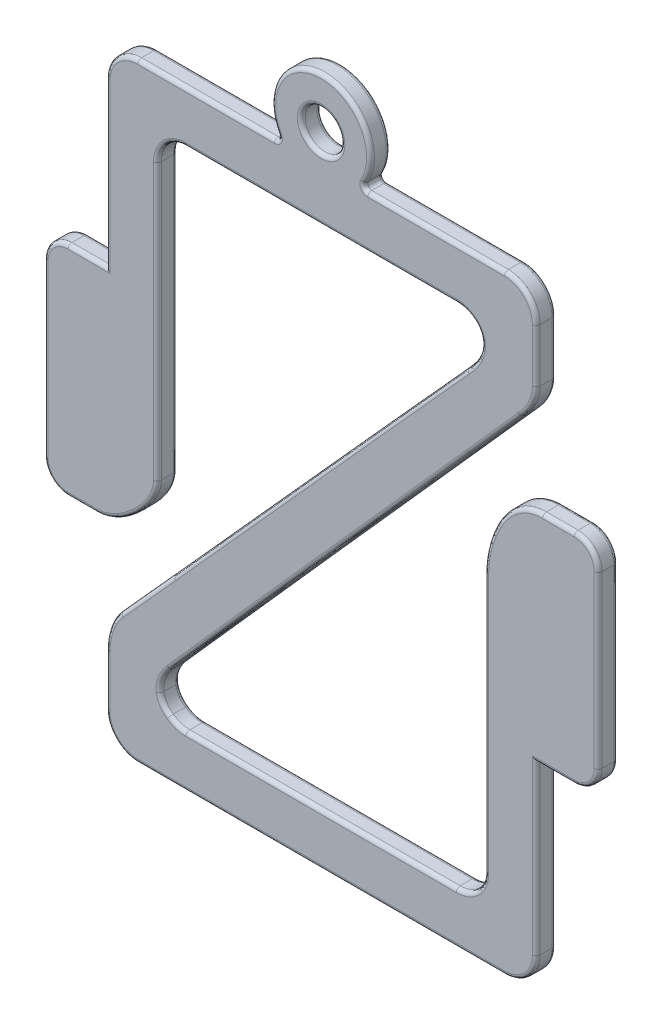
from build123d import *

# Parameters (mm, degrees)
MODEL_R             = 10
BOSS_EXTRUDE1_DEPTH = 10
FILLET1_R           = 2
SCALE1_SCALE        = 0.12


with BuildPart() as part:
    # Model → Boss-Extrude1 (new body)
    with BuildSketch(Plane.XY):
        with BuildLine():
            Line((214.526068033, -387.721577334), (400.098290163, -387.721577334))
            add(Edge.make_bspline(
                [(400.098290163, -387.721577334), (408.979915984, -387.721577334), (416.18012087, -380.521372266), (416.18012087, -371.639746221)],
                knots=[1, 1, 1, 1, 2, 2, 2, 2], degree=3))
            Line((416.18012087, -371.639746221), (416.18012087, -286.435471139))
            Line((416.18012087, -286.435471139), (435.328118703, -286.435471139))
            add(Edge.make_bspline(
                [(435.328118703, -286.435471139), (442.036770379, -286.435471139), (447.475543253, -280.996698128), (447.475543253, -274.288046283)],
                knots=[4, 4, 4, 4, 5, 5, 5, 5], degree=3))
            Line((447.475543253, -274.288046283), (447.475543253, -188.08165222))
            add(Edge.make_bspline(
                [(447.475543253, -188.08165222), (447.475543253, -181.373396469), (442.10093768, -175.935019553), (435.392682099, -175.934227364)],
                knots=[6, 6, 6, 6, 7, 7, 7, 7], degree=3))
            add(Edge.make_bspline(
                [(435.392682099, -175.934227364), (431.212301288, -175.933435175), (425.969991261, -175.933435175), (419.396011698, -175.933435175)],
                knots=[7, 7, 7, 7, 8, 8, 8, 8], degree=3))
            add(Edge.make_bspline(
                [(419.396011698, -175.933435175), (398.673934526, -175.933435175), (390.071951386, -201.860194057), (390.071951386, -215.744097019)],
                knots=[8, 8, 8, 8, 9, 9, 9, 9], degree=3))
            Line((390.071951386, -215.744097019), (390.071951386, -347.210620487))
            add(Edge.make_bspline(
                [(390.071951386, -347.210620487), (390.071951386, -355.164989405), (383.623533763, -361.613407191), (375.669165046, -361.613407191)],
                knots=[10, 10, 10, 10, 11, 11, 11, 11], degree=3))
            Line((375.669165046, -361.613407191), (238.938161705, -361.613407191))
            add(Edge.make_bspline(
                [(238.938161705, -361.613407191), (235.808619388, -361.613407191), (232.921090785, -360.679416457), (230.569477984, -358.898575771)],
                knots=[12, 12, 12, 12, 13, 13, 13, 13], degree=3))
            add(Edge.make_bspline(
                [(230.569477984, -358.898575771), (227.915645111, -357.04881465), (226.229867096, -354.420727917), (225.832188259, -351.394566253)],
                knots=[13, 13, 13, 13, 14, 14, 14, 14], degree=3))
            add(Edge.make_bspline(
                [(225.832188259, -351.394566253), (225.313304519, -347.487094419), (226.981654378, -343.216403967), (230.77703148, -338.7036998)],
                knots=[14, 14, 14, 14, 15, 15, 15, 15], degree=3))
            add(Edge.make_bspline(
                [(230.77703148, -338.7036998), (236.119553538, -332.340838417), (376.378174109, -175.12104544), (382.342960411, -168.429425657)],
                knots=[15, 15, 15, 15, 16, 16, 16, 16], degree=3))
            Line((382.342960411, -168.429425657), (408.503414362, -139.044762152))
            add(Edge.make_bspline(
                [(408.503414362, -139.044762152), (408.831789074, -138.707685768), (416.18012087, -131.549466712), (416.18012087, -122.342647116)],
                knots=[17, 17, 17, 17, 18, 18, 18, 18], degree=3))
            Line((416.18012087, -122.342647116), (416.18012087, -95.414957538))
            add(Edge.make_bspline(
                [(416.18012087, -95.414957538), (416.18012087, -86.569772183), (408.943475294, -79.333126425), (400.098290163, -79.333126425)],
                knots=[19, 19, 19, 19, 20, 20, 20, 20], degree=3))
            Line((400.098290163, -79.333126425), (327.201708722, -79.333126425))
            ThreePointArc((327.201708722, -79.333126425), (307.307822059, -39.192674865), (287.413935396, -79.333126425))
            Line((287.413935396, -79.333126425), (214.517353955, -79.333126425))
            add(Edge.make_bspline(
                [(214.517353955, -79.333126425), (205.672564695, -79.333126425), (198.435522842, -86.569772183), (198.435522842, -95.414957538)],
                knots=[21, 21, 21, 21, 22, 22, 22, 22], degree=3))
            Line((198.435522842, -95.414957538), (198.435522842, -177.95668567))
            Line((198.435522842, -177.95668567), (179.287524525, -177.95668567))
            add(Edge.make_bspline(
                [(179.287524525, -177.95668567), (172.578872679, -177.95668567), (167.140495763, -183.395062586), (167.140495763, -190.103714431)],
                knots=[24, 24, 24, 24, 25, 25, 25, 25], degree=3))
            Line((167.140495763, -190.103714431), (167.140495763, -276.293868621))
            add(Edge.make_bspline(
                [(167.140495763, -276.293868621), (167.140495763, -283.002520466), (172.578872679, -288.440897383), (179.287524525, -288.440897383)],
                knots=[26, 26, 26, 26, 27, 27, 27, 27], degree=3))
            Line((179.287524525, -288.440897383), (194.009167267, -288.440897383))
            add(Edge.make_bspline(
                [(194.009167267, -288.440897383), (206.562192849, -288.440897383), (224.543692985, -271.375563729), (224.543692985, -259.445198636)],
                knots=[28, 28, 28, 28, 29, 29, 29, 29], degree=3))
            Line((224.543692985, -259.445198636), (224.543692985, -119.835369194))
            add(Edge.make_bspline(
                [(224.543692985, -119.835369194), (224.543692985, -111.88575341), (230.988545921, -105.441296568), (238.938161705, -105.441296568)],
                knots=[30, 30, 30, 30, 31, 31, 31, 31], degree=3))
            Line((238.938161705, -105.441296568), (375.677879124, -105.441296568))
            add(Edge.make_bspline(
                [(375.677879124, -105.441296568), (378.789993207, -105.441296568), (381.677521737, -106.374891207), (384.028738384, -108.138699831)],
                knots=[32, 32, 32, 32, 33, 33, 33, 33], degree=3))
            add(Edge.make_bspline(
                [(384.028738384, -108.138699831), (386.510270104, -109.867652143), (388.118017471, -112.582087468), (388.438061785, -115.694201629)],
                knots=[33, 33, 33, 33, 34, 34, 34, 34], degree=3))
            add(Edge.make_bspline(
                [(388.438061785, -115.694201629), (388.939517357, -120.526950118), (386.458381731, -125.783123584), (380.856021851, -131.74830613)],
                knots=[34, 34, 34, 34, 35, 35, 35, 35], degree=3))
            add(Edge.make_bspline(
                [(380.856021851, -131.74830613), (372.081341531, -141.119504926), (233.655846005, -295.011312262), (232.263970078, -296.567567389)],
                knots=[35, 35, 35, 35, 36, 36, 36, 36], degree=3))
            Line((232.263970078, -296.567567389), (205.706232724, -325.977977034))
            add(Edge.make_bspline(
                [(205.706232724, -325.977977034), (205.196063061, -326.479432619), (198.435522842, -333.222544682), (198.435522842, -346.519039563)],
                knots=[37, 37, 37, 37, 38, 38, 38, 38], degree=3))
            Line((198.435522842, -346.519039563), (198.435522842, -371.631032143))
            add(Edge.make_bspline(
                [(198.435522842, -371.631032143), (198.435522842, -380.480970631), (205.676129545, -387.721577334), (214.526068033, -387.721577334)],
                knots=[39, 39, 39, 39, 40, 40, 40, 40], degree=3))
        make_face()
        with Locations((307.307822059, -64.192674865)):
            Circle(MODEL_R, mode=Mode.SUBTRACT)
    extrude(amount=BOSS_EXTRUDE1_DEPTH)

    # Fillet1
    fillet1_edges = [part.edges().sort_by_distance(p)[0] for p in [
        (380.075334197, -106.108284587, 10),
        (250.965644676, -79.333126425, 10),
        (203.159565855, -84.057174043, 10),
        (198.435522842, -136.685821604, 10),
        (188.861523683, -177.95668567, 10),
        (170.698265701, -181.514455609, 10),
        (167.140495763, -233.198791526, 10),
        (170.698265703, -284.883127444, 10),
        (186.648345896, -288.440897383, 10),
        (213.769933069, -278.618765258, 10),
        (224.543692985, -189.640283915, 10),
        (387.063318177, -111.43095014, 10),
        (386.344695798, -124.456899716, 10),
        (306.488719566, -214.093514007, 10),
        (218.985101401, -311.272772212, 10),
        (200.155205665, -335.548848808, 10),
        (198.435522842, -359.075035853, 10),
        (203.162068506, -382.995031673, 10),
        (307.312179098, -387.721577334, 10),
        (224.543692985, -189.640283915, 0),
        (213.769933069, -278.618765258, 0),
        (186.648345896, -288.440897383, 0),
        (170.698265703, -284.883127444, 0),
        (167.140495763, -233.198791526, 0),
        (170.698265701, -181.514455609, 0),
        (411.469815272, -383.011271472, 10),
        (188.861523683, -177.95668567, 0),
        (198.435522842, -136.685821604, 0),
        (203.159565855, -84.057174043, 0),
        (250.965644676, -79.333126425, 0),
        (307.307822059, -39.192674865, 0),
        (363.649999442, -79.333126425, 0),
        (411.456150011, -84.057097543, 0),
        (228.75984915, -109.657199239, 10),
        (416.18012087, -329.03760868, 10),
        (416.18012087, -108.878802327, 0),
        (413.928974503, -131.399663699, 0),
        (395.423187386, -153.737093904, 0),
        (306.491025109, -253.505377343, 0),
        (226.980933679, -344.569611369, 0),
        (227.394808212, -355.65038639, 0),
        (234.528232142, -360.945058643, 0),
        (307.303663376, -361.613407191, 0),
        (425.754119787, -286.435471139, 10),
        (385.853446548, -357.39490212, 0),
        (390.071951386, -281.477358753, 0),
        (397.439618406, -189.826945623, 0),
        (427.394346919, -175.933504679, 0),
        (443.954119219, -179.497086374, 0),
        (447.475543253, -231.184849251, 0),
        (443.917575412, -282.877503098, 0),
        (443.917575412, -282.877503098, 10),
        (425.754119787, -286.435471139, 0),
        (416.18012087, -329.03760868, 0),
        (411.469815272, -383.011271472, 0),
        (307.312179098, -387.721577334, 0),
        (203.162068506, -382.995031673, 0),
        (198.435522842, -359.075035853, 0),
        (200.155205665, -335.548848808, 0),
        (218.985101401, -311.272772212, 0),
        (447.475543253, -231.184849251, 10),
        (306.488719566, -214.093514007, 0),
        (386.344695798, -124.456899716, 0),
        (387.063318177, -111.43095014, 0),
        (380.075334197, -106.108284587, 0),
        (307.308020415, -105.441296568, 0),
        (228.75984915, -109.657199239, 0),
        (443.954119219, -179.497086374, 10),
        (427.394346919, -175.933504679, 10),
        (397.439618406, -189.826945623, 10),
        (390.071951386, -281.477358753, 10),
        (385.853446548, -357.39490212, 10),
        (287.413935396, -79.333126425, 5),
        (327.201708722, -79.333126425, 5),
        (307.303663376, -361.613407191, 10),
        (307.308020415, -105.441296568, 10),
        (234.528232142, -360.945058643, 10),
        (227.394808212, -355.65038639, 10),
        (226.980933679, -344.569611369, 10),
        (306.491025109, -253.505377343, 10),
        (395.423187386, -153.737093904, 10),
        (413.928974503, -131.399663699, 10),
        (416.18012087, -108.878802327, 10),
        (411.456150011, -84.057097543, 10),
        (363.649999442, -79.333126425, 10),
        (297.307822059, -64.192674865, 0),
        (297.307822059, -64.192674865, 10),
        (307.307822059, -39.192674865, 10),
    ]]
    fillet(fillet1_edges, radius=FILLET1_R)


with BuildPart() as part_1:
    # Scale1: scaled about (307.208449103, -226.978489969, 5)
    add(part.part.scale(SCALE1_SCALE).moved(Location((270.343435211, -199.741071173, 4.4))))


solid = part_1.part
